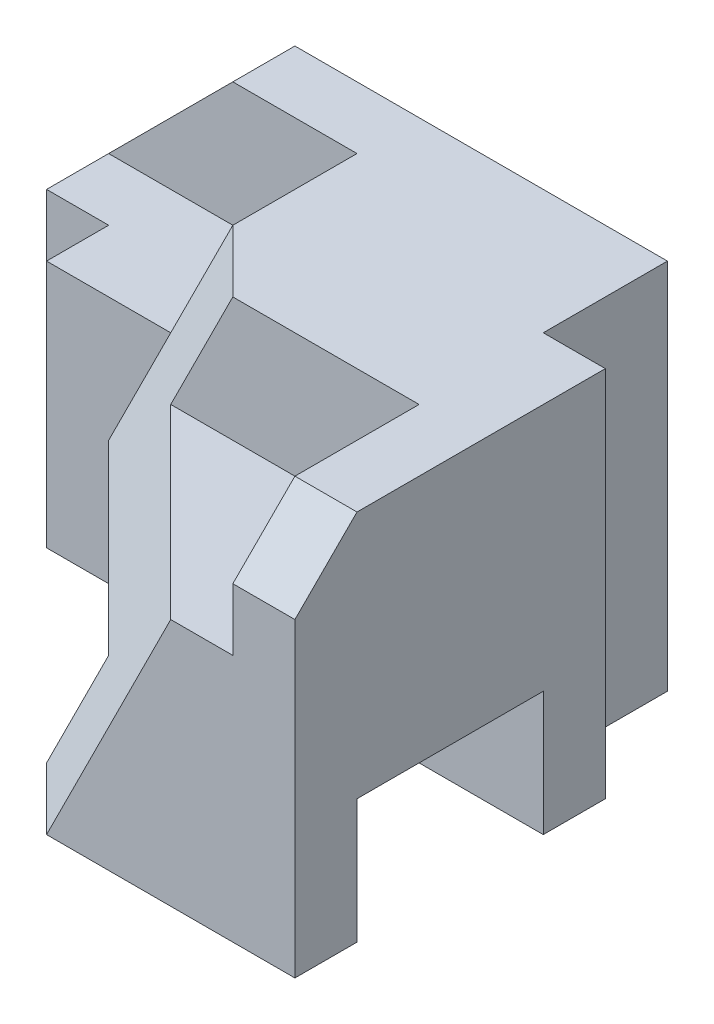
from build123d import *

# Parameters (mm, degrees)
SKETCH1_W               = 9
SKETCH1_H               = 7
BOSS_EXTRUDE1_DEPTH     = 6
SKETCH2_W               = 3
SKETCH2_H               = 2
CUT_EXTRUDE1_DEPTH      = 12.368817001
SKETCH3_W               = 3
SKETCH3_H               = 2
CUT_EXTRUDE2_DEPTH      = 8
CHAMFER1_SIZE           = 1
SKETCH4_W               = 1
SKETCH4_H               = 2
CUT_EXTRUDE3_DEPTH      = 9.276472679
SKETCH5_W               = 3
SKETCH5_H               = 2
CUT_EXTRUDE4_DEPTH      = 2
CHAMFER2_SIZE           = 2
CUT_EXTRUDE5_DEPTH      = 2
CUT_EXTRUDE5_DEPTH_BACK = 1
CUT_EXTRUDE6_DEPTH      = 5.094054233
CUT_EXTRUDE7_DEPTH      = 5.094054233


with BuildPart() as part:
    # Sketch1 → Boss-Extrude1 (new body)
    with BuildSketch(Plane(origin=(0, 0, 0), x_dir=(1, 0, 0), z_dir=(0, 1, 0))):
        Rectangle(SKETCH1_W, SKETCH1_H)
    extrude(amount=BOSS_EXTRUDE1_DEPTH)

    # Sketch2 → Cut-Extrude1 (cut, through all)
    with BuildSketch(Plane.ZY.offset(4.5)):
        with Locations((1, 1)):
            Rectangle(SKETCH2_W, SKETCH2_H)
    extrude(amount=-CUT_EXTRUDE1_DEPTH, mode=Mode.SUBTRACT)

    # Sketch3 → Cut-Extrude2 (cut)
    with BuildSketch(Plane.ZY.offset(4.5)):
        with Locations((2, 5)):
            Rectangle(SKETCH3_W, SKETCH3_H)
    extrude(amount=-CUT_EXTRUDE2_DEPTH, mode=Mode.SUBTRACT)

    # Chamfer1
    chamfer1_edges = [part.edges().sort_by_distance(p)[0] for p in [
        (4, 6, 3.5),
    ]]
    chamfer(chamfer1_edges, length=CHAMFER1_SIZE)

    # Sketch4 → Cut-Extrude3 (cut, through all)
    with BuildSketch(Plane(origin=(0, 6, 0), x_dir=(1, 0, 0), z_dir=(0, 1, 0))):
        with Locations((4, 2.5)):
            Rectangle(SKETCH4_W, SKETCH4_H)
    extrude(amount=-CUT_EXTRUDE3_DEPTH, mode=Mode.SUBTRACT)

    # Sketch5 → Cut-Extrude4 (cut)
    with BuildSketch(Plane(origin=(0, 6, 0), x_dir=(1, 0, 0), z_dir=(0, 1, 0))):
        with Locations((-3, 0.5)):
            Rectangle(SKETCH5_W, SKETCH5_H)
    extrude(amount=-CUT_EXTRUDE4_DEPTH, mode=Mode.SUBTRACT)

    # Chamfer2
    chamfer2_edges = [part.edges().sort_by_distance(p)[0] for p in [
        (-4.5, 6, -2.5),
    ]]
    chamfer(chamfer2_edges, length=CHAMFER2_SIZE)

    # Sketch6 → Cut-Extrude5 (cut, two sides)
    with BuildSketch(Plane.XY.offset(-1.5)) as cut_extrude5_sk:
        Polygon((-4.5, 4), (-2.5, 6), (-0.5, 6), (-1.5, 4), align=None)
    extrude(amount=CUT_EXTRUDE5_DEPTH, mode=Mode.SUBTRACT)
    extrude(cut_extrude5_sk.sketch, amount=-CUT_EXTRUDE5_DEPTH_BACK, mode=Mode.SUBTRACT)

    # Sketch7 → Cut-Extrude6 (cut)
    with BuildSketch(Plane(origin=(0, 4, 0), x_dir=(1, 0, 0), z_dir=(0, 1, 0))):
        Polygon((-4.5, 1.5), (-3.5, 1.5), (-3.5, 0.5), (-2.5, 0.5), (-2.5, -3.5), (-4.5, -3.5), align=None)
    extrude(amount=-CUT_EXTRUDE6_DEPTH, mode=Mode.SUBTRACT)

    # 3DSketch1 → Cut-Extrude7 (cut, along a direction that is not the sketch's normal)
    with BuildSketch(Plane(origin=(2.5, 4, 3.5), x_dir=(-0.7453559924999292, -0.29814239699997236, -0.5962847939999446), z_dir=(0.6666666666666674, -0.33333333333333376, -0.6666666666666657))):
        Polygon((0, 0), (2.683281573, -3.577708764), (4.024922359, -3.130495168), (2.683281573, -1.341640786), (6.708203932, 0), (4.024922359, 3.577708764), (2.683281573, 3.130495168), (4.024922359, 1.341640786), align=None)
    extrude(amount=-CUT_EXTRUDE7_DEPTH, dir=(1, 0, 0), mode=Mode.SUBTRACT)


solid = part.part
